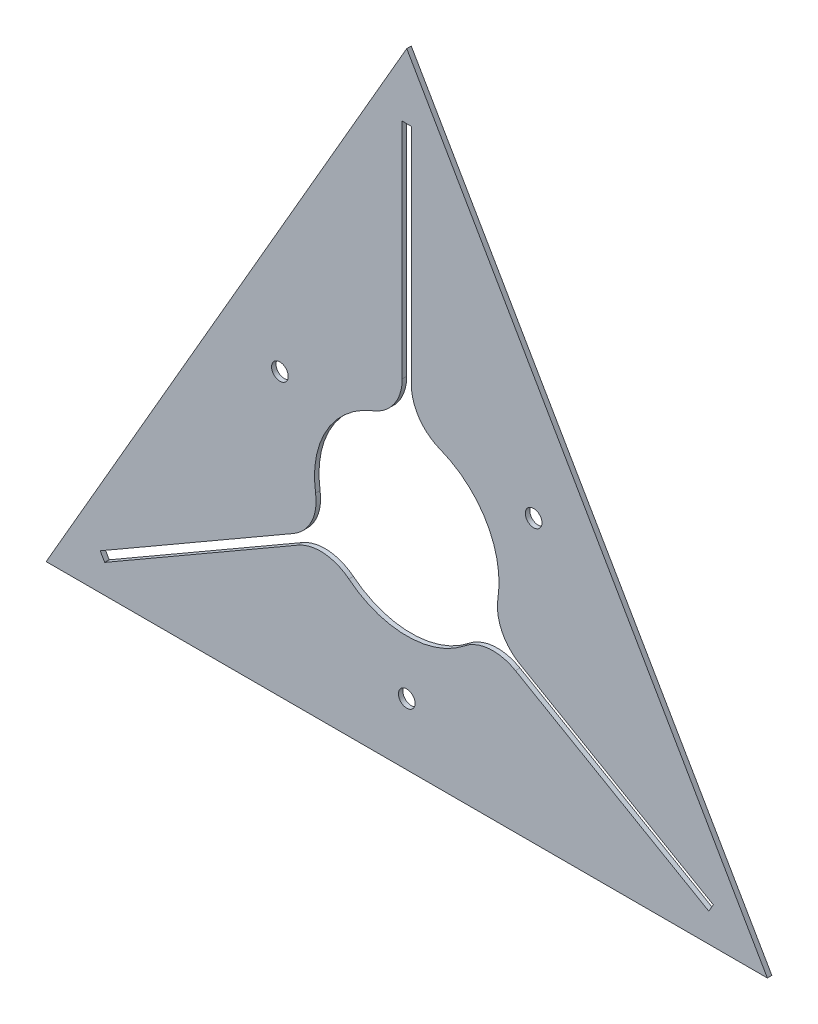
from build123d import *

# Parameters (mm, degrees)
SKETCH1_R           = 4.699
BOSS_EXTRUDE1_DEPTH = 2.54


with BuildPart() as part:
    # Sketch1 → Boss-Extrude1 (new body)
    with BuildSketch(Plane.XY):
        Polygon((0, 234.635149399), (-203.2, -117.317574699), (203.2, -117.317574699), align=None)
        with Locations((0, -82.55)):
            Circle(SKETCH1_R, mode=Mode.SUBTRACT)
        with Locations((-71.490397082, 41.275)):
            Circle(SKETCH1_R, mode=Mode.SUBTRACT)
        with Locations((71.490397082, 41.275)):
            Circle(SKETCH1_R, mode=Mode.SUBTRACT)
        with BuildLine():
            Line((-2.54, 72.188105961), (-2.54, 197.994436105))
            Line((-2.54, 197.994436105), (2.54, 197.994436105))
            Line((2.54, 197.994436105), (2.54, 72.188105961))
            ThreePointArc((2.54, 72.188105961), (6.987296904, 57.830382152), (18.771829368, 48.500458394))
            ThreePointArc((18.771829368, 48.500458394), (45.038950162, 26.00325), (51.388543748, -7.993348088))
            ThreePointArc((51.388543748, -7.993348088), (53.576228506, -22.864014453), (63.786733613, -33.894348455))
            Line((63.786733613, -33.894348455), (172.738211475, -96.797513527))
            Line((172.738211475, -96.797513527), (170.198211475, -101.196922578))
            Line((170.198211475, -101.196922578), (61.246733613, -38.293757506))
            ThreePointArc((61.246733613, -38.293757506), (46.588931602, -34.966367699), (32.61671438, -40.507110305))
            ThreePointArc((32.61671438, -40.507110305), (0, -52.0065), (-32.61671438, -40.507110305))
            ThreePointArc((-32.61671438, -40.507110305), (-46.588931602, -34.966367699), (-61.246733613, -38.293757506))
            Line((-61.246733613, -38.293757506), (-170.198211475, -101.196922578))
            Line((-170.198211475, -101.196922578), (-172.738211475, -96.797513527))
            Line((-172.738211475, -96.797513527), (-63.786733613, -33.894348455))
            ThreePointArc((-63.786733613, -33.894348455), (-53.576228506, -22.864014453), (-51.388543748, -7.993348088))
            ThreePointArc((-51.388543748, -7.993348088), (-45.038950162, 26.00325), (-18.771829368, 48.500458394))
            ThreePointArc((-18.771829368, 48.500458394), (-6.987296904, 57.830382152), (-2.54, 72.188105961))
        make_face(mode=Mode.SUBTRACT)
    extrude(amount=BOSS_EXTRUDE1_DEPTH)


solid = part.part
